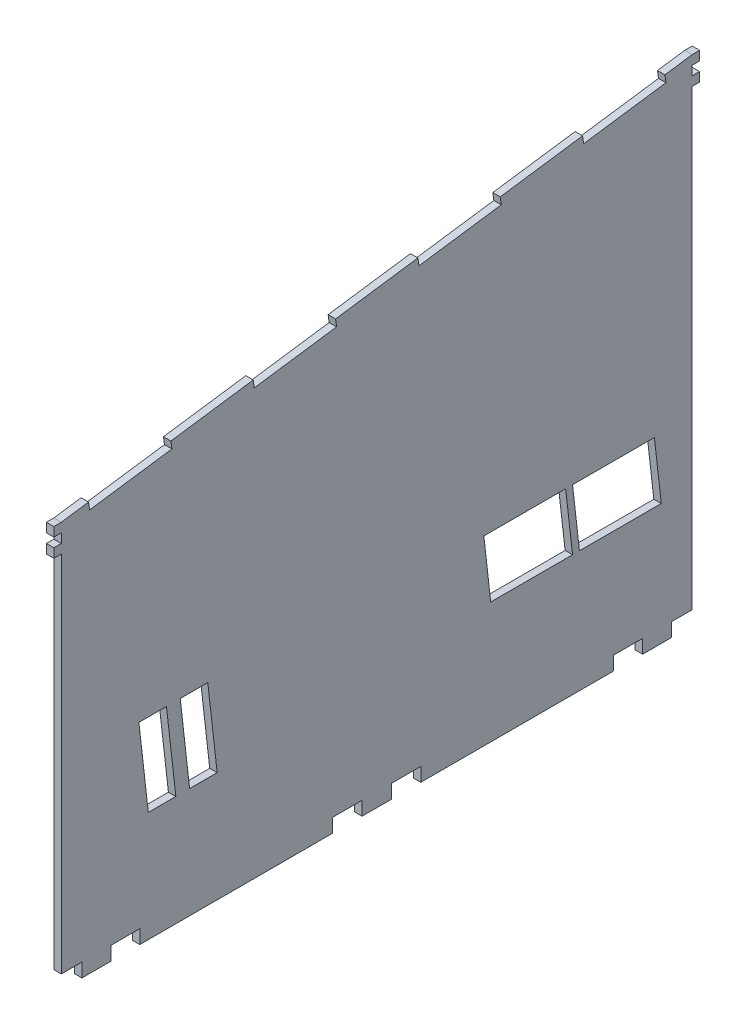
from build123d import *

# Parameters (mm, degrees)
BOSS_EXTRUDE1_DEPTH = 2.7


with BuildPart() as part:
    # Sketch1 → Boss-Extrude1 (new body)
    with BuildSketch(Plane(origin=(0, 0, 0), x_dir=(0, 0, -1), z_dir=(1, 0, 0))):
        Polygon((-107.013333333, -114.8), (-96.506666667, -114.8), (-96.506666667, -109.8), (-86, -109.8), (-86, -114.8), (-16, -114.8), (-16, -109.8), (-5.333333333, -109.8), (-5.333333333, -114.8), (5.333333333, -114.8), (5.333333333, -109.8), (16, -109.8), (16, -114.8), (86, -114.8), (86, -109.8), (96.506666667, -109.8), (96.506666667, -114.8), (107.013333333, -114.8), (107.013333333, -109.8), (114.49, -109.8), (114.5, 54.7), (117.2, 54.7), (117.2, 58.033333333), (114.5, 58.033333333), (114.5, 61.366666667), (117.2, 61.366666667), (117.2, 64.7), (114.5, 64.7), (104.599212181, 63.294866357), (104.978598264, 60.621653646), (75.09310907, 56.380263258), (74.713722986, 59.05347597), (44.828233792, 54.812085582), (45.207619875, 52.138872871), (15.322130681, 47.897482483), (14.942744597, 50.570695194), (-14.942744597, 46.329304806), (-14.563358514, 43.656092095), (-44.448847708, 39.414701707), (-44.828233792, 42.087914418), (-74.713722986, 37.84652403), (-74.334336903, 35.173311319), (-104.219826097, 30.931920931), (-104.599212181, 33.605133643), (-114.5, 32.2), (-117.2, 32.2), (-117.2, 28.866666667), (-114.5, 28.866666667), (-114.5, 25.533333333), (-117.2, 25.533333333), (-117.2, 22.2), (-114.5, 22.2), (-114.5, -109.8), (-107.013333333, -109.8), align=None)
        Polygon((100.78, -48.8), (71.08, -48.8), (73.58, -70.8), (100.78, -70.8), (103.28, -70.8), align=None, mode=Mode.SUBTRACT)
        Polygon((68.58, -48.8), (71.08, -70.8), (41.38, -70.8), (38.88, -48.8), (41.38, -48.8), align=None, mode=Mode.SUBTRACT)
        Polygon((-72.910909091, -74.8), (-76.32, -44.8), (-86.32, -44.8), (-82.910909091, -74.8), align=None, mode=Mode.SUBTRACT)
        Polygon((-67.910909091, -74.8), (-71.32, -44.8), (-61.32, -44.8), (-57.910909091, -74.8), align=None, mode=Mode.SUBTRACT)
    extrude(amount=BOSS_EXTRUDE1_DEPTH)


solid = part.part
